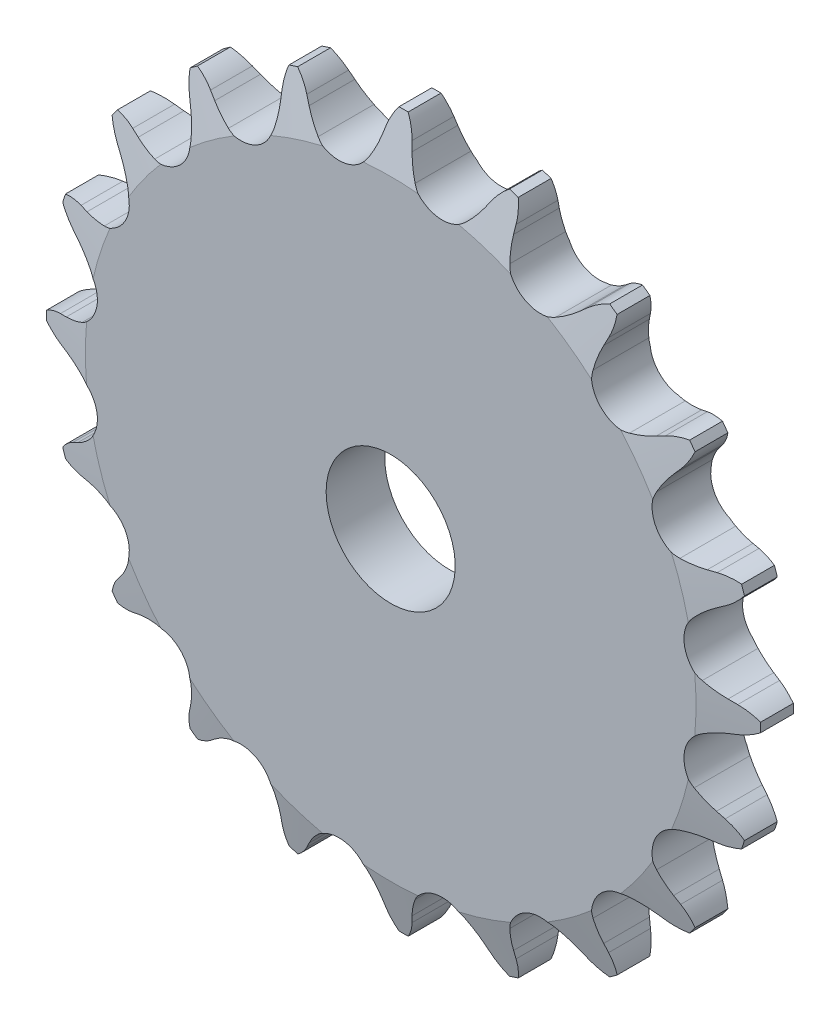
from build123d import *

# Parameters (mm, degrees)
CUT_EXTRUDE1_DEPTH      = 63.191935016
CIRPATTERN1_COUNT       = 20
CUT_EXTRUDE2_DEPTH      = 63.191935163
CUT_EXTRUDE2_DEPTH_BACK = 63.191935163
SKETCH3_OUTSIDE_W       = 114.68
SKETCH3_OUTSIDE_H       = 114.68
SKETCH3_OUTSIDE_R       = 43.942
SKETCH3_OUTSIDE_R_2     = 7.9375


with BuildPart() as part:
    # Sketch1 → Revolve1 (revolve)
    with BuildSketch(Plane(origin=(0, 0, 0), x_dir=(0, 0, -1), z_dir=(1, 0, 0)), mode=Mode.PRIVATE) as revolve1_sk:
        Polygon((3.6068, 0), (-3.6068, 0), (-3.6068, 37.552322118), (-2.0193, 43.902322118), (2.0193, 43.902322118), (3.6068, 37.552322118), align=None)
    revolve(revolve1_sk.sketch.rotate(Axis((0, 0, -3.6068), (0, 0, 1)), 90), axis=Axis((0, 0, -3.6068), (0, 0, 1)))

    # Sketch0 → Cut-Extrude1 (cut, symmetric)
    with BuildSketch(Plane.XY):
        with BuildLine():
            Line((11.349899794, -40.106130625), (10.831257, -39.269645431))
            ThreePointArc((10.831257, -39.269645431), (10.031876794, -38.153082974), (9.091846191, -37.152052055))
            ThreePointArc((9.091846191, -37.152052055), (5.721084643, -36.12150683), (2.833755896, -38.143236184))
            ThreePointArc((2.833755896, -38.143236184), (2.249069231, -39.385758594), (1.833850252, -40.694694663))
            Line((1.833850252, -40.694694663), (1.599079784, -41.650508795))
            ThreePointArc((1.599079784, -41.650508795), (-1.023603332, -45.461216991), (-5.512433901, -46.579413668))
            ThreePointArc((-5.512433901, -46.579413668), (7.337474671, -46.326991815), (19.636466594, -42.596219139))
            ThreePointArc((19.636466594, -42.596219139), (15.021793255, -42.919875833), (11.349899794, -40.106130625))
        make_face()
    cut_extrude1 = extrude(amount=CUT_EXTRUDE1_DEPTH, both=True, mode=Mode.SUBTRACT)

    # CirPattern1: Cut-Extrude1 ×20 about axis
    cirpattern1_axis = Axis((0, 0, 0), (0, 0, 1))
    for i in range(1, CIRPATTERN1_COUNT):
        add(cut_extrude1.rotate(cirpattern1_axis, i * 360 / CIRPATTERN1_COUNT), mode=Mode.SUBTRACT)

    # Sketch3 outside → Cut-Extrude2 (cut, two sides: drawn at the far end of the back side and taken through both)
    # profile 1 of 2: a face of its own
    with BuildSketch(Plane.XY.offset(-CUT_EXTRUDE2_DEPTH_BACK)):
        Rectangle(SKETCH3_OUTSIDE_W, SKETCH3_OUTSIDE_H)
        Circle(SKETCH3_OUTSIDE_R, mode=Mode.SUBTRACT)
    # profile 2 of 2: a face of its own
    with BuildSketch(Plane.XY.offset(-CUT_EXTRUDE2_DEPTH_BACK)):
        with Locations(Location((0, 0, 0), (0, 0, 180))):
            Circle(SKETCH3_OUTSIDE_R_2)
    extrude(amount=CUT_EXTRUDE2_DEPTH + CUT_EXTRUDE2_DEPTH_BACK, mode=Mode.SUBTRACT)


solid = part.part
